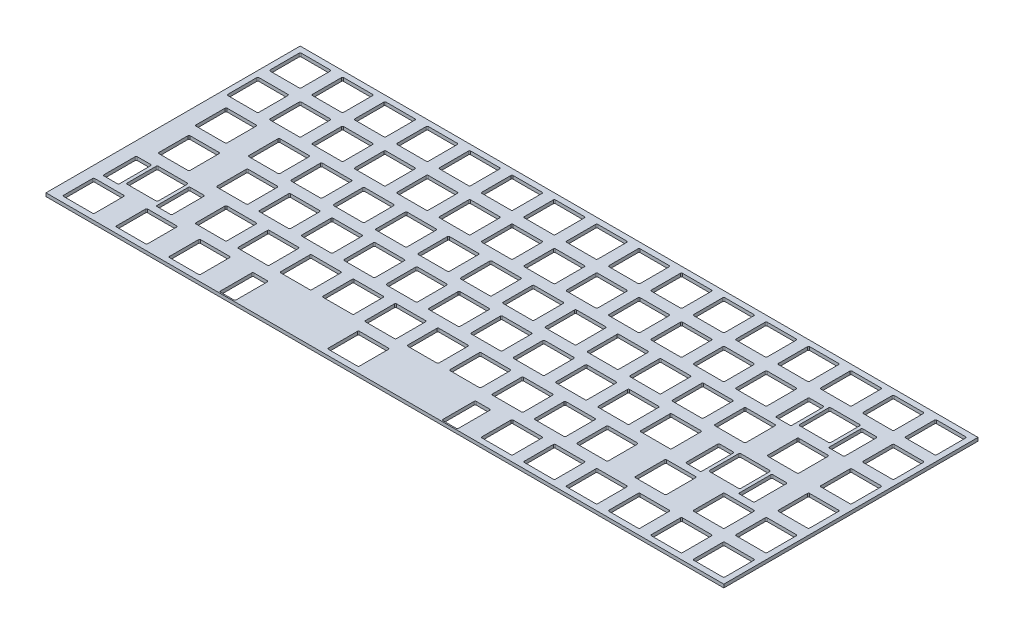
from build123d import *

# Parameters (mm, degrees)
SKETCH2_W           = 304.8
SKETCH2_H           = 114.3
BOSS_EXTRUDE1_DEPTH = 1.5


with BuildPart() as part:
    # Sketch2 → Boss-Extrude1 (new body)
    with BuildSketch(Plane(origin=(0, 0, 0), x_dir=(1, 0, 0), z_dir=(0, 1, 0))):
        with Locations((152.4, -57.15)):
            Rectangle(SKETCH2_W, SKETCH2_H)
        with BuildLine():
            Line((3.025, -2.525), (16.025, -2.525))
            ThreePointArc((16.025, -2.525), (16.378553391, -2.671446609), (16.525, -3.025))
            Line((16.525, -3.025), (16.525, -16.025))
            ThreePointArc((16.525, -16.025), (16.378553391, -16.378553391), (16.025, -16.525))
            Line((16.025, -16.525), (3.025, -16.525))
            ThreePointArc((3.025, -16.525), (2.671446609, -16.378553391), (2.525, -16.025))
            Line((2.525, -16.025), (2.525, -3.025))
            ThreePointArc((2.525, -3.025), (2.671446609, -2.671446609), (3.025, -2.525))
        make_face(mode=Mode.SUBTRACT)
        with BuildLine():
            Line((22.075, -2.525), (35.075, -2.525))
            ThreePointArc((35.075, -2.525), (35.428553391, -2.671446609), (35.575, -3.025))
            Line((35.575, -3.025), (35.575, -16.025))
            ThreePointArc((35.575, -16.025), (35.428553391, -16.378553391), (35.075, -16.525))
            Line((35.075, -16.525), (22.075, -16.525))
            ThreePointArc((22.075, -16.525), (21.721446609, -16.378553391), (21.575, -16.025))
            Line((21.575, -16.025), (21.575, -3.025))
            ThreePointArc((21.575, -3.025), (21.721446609, -2.671446609), (22.075, -2.525))
        make_face(mode=Mode.SUBTRACT)
        with BuildLine():
            Line((41.125, -2.525), (54.125, -2.525))
            ThreePointArc((54.125, -2.525), (54.478553391, -2.671446609), (54.625, -3.025))
            Line((54.625, -3.025), (54.625, -16.025))
            ThreePointArc((54.625, -16.025), (54.478553391, -16.378553391), (54.125, -16.525))
            Line((54.125, -16.525), (41.125, -16.525))
            ThreePointArc((41.125, -16.525), (40.771446609, -16.378553391), (40.625, -16.025))
            Line((40.625, -16.025), (40.625, -3.025))
            ThreePointArc((40.625, -3.025), (40.771446609, -2.671446609), (41.125, -2.525))
        make_face(mode=Mode.SUBTRACT)
        with BuildLine():
            Line((60.175, -2.525), (73.175, -2.525))
            ThreePointArc((73.175, -2.525), (73.528553391, -2.671446609), (73.675, -3.025))
            Line((73.675, -3.025), (73.675, -16.025))
            ThreePointArc((73.675, -16.025), (73.528553391, -16.378553391), (73.175, -16.525))
            Line((73.175, -16.525), (60.175, -16.525))
            ThreePointArc((60.175, -16.525), (59.821446609, -16.378553391), (59.675, -16.025))
            Line((59.675, -16.025), (59.675, -3.025))
            ThreePointArc((59.675, -3.025), (59.821446609, -2.671446609), (60.175, -2.525))
        make_face(mode=Mode.SUBTRACT)
        with BuildLine():
            Line((79.225, -2.525), (92.225, -2.525))
            ThreePointArc((92.225, -2.525), (92.578553391, -2.671446609), (92.725, -3.025))
            Line((92.725, -3.025), (92.725, -16.025))
            ThreePointArc((92.725, -16.025), (92.578553391, -16.378553391), (92.225, -16.525))
            Line((92.225, -16.525), (79.225, -16.525))
            ThreePointArc((79.225, -16.525), (78.871446609, -16.378553391), (78.725, -16.025))
            Line((78.725, -16.025), (78.725, -3.025))
            ThreePointArc((78.725, -3.025), (78.871446609, -2.671446609), (79.225, -2.525))
        make_face(mode=Mode.SUBTRACT)
        with BuildLine():
            Line((98.275, -2.525), (111.275, -2.525))
            ThreePointArc((111.275, -2.525), (111.628553391, -2.671446609), (111.775, -3.025))
            Line((111.775, -3.025), (111.775, -16.025))
            ThreePointArc((111.775, -16.025), (111.628553391, -16.378553391), (111.275, -16.525))
            Line((111.275, -16.525), (98.275, -16.525))
            ThreePointArc((98.275, -16.525), (97.921446609, -16.378553391), (97.775, -16.025))
            Line((97.775, -16.025), (97.775, -3.025))
            ThreePointArc((97.775, -3.025), (97.921446609, -2.671446609), (98.275, -2.525))
        make_face(mode=Mode.SUBTRACT)
        with BuildLine():
            Line((117.325, -2.525), (130.325, -2.525))
            ThreePointArc((130.325, -2.525), (130.678553391, -2.671446609), (130.825, -3.025))
            Line((130.825, -3.025), (130.825, -16.025))
            ThreePointArc((130.825, -16.025), (130.678553391, -16.378553391), (130.325, -16.525))
            Line((130.325, -16.525), (117.325, -16.525))
            ThreePointArc((117.325, -16.525), (116.971446609, -16.378553391), (116.825, -16.025))
            Line((116.825, -16.025), (116.825, -3.025))
            ThreePointArc((116.825, -3.025), (116.971446609, -2.671446609), (117.325, -2.525))
        make_face(mode=Mode.SUBTRACT)
        with BuildLine():
            Line((136.375, -2.525), (149.375, -2.525))
            ThreePointArc((149.375, -2.525), (149.728553391, -2.671446609), (149.875, -3.025))
            Line((149.875, -3.025), (149.875, -16.025))
            ThreePointArc((149.875, -16.025), (149.728553391, -16.378553391), (149.375, -16.525))
            Line((149.375, -16.525), (136.375, -16.525))
            ThreePointArc((136.375, -16.525), (136.021446609, -16.378553391), (135.875, -16.025))
            Line((135.875, -16.025), (135.875, -3.025))
            ThreePointArc((135.875, -3.025), (136.021446609, -2.671446609), (136.375, -2.525))
        make_face(mode=Mode.SUBTRACT)
        with BuildLine():
            Line((155.425, -2.525), (168.425, -2.525))
            ThreePointArc((168.425, -2.525), (168.778553391, -2.671446609), (168.925, -3.025))
            Line((168.925, -3.025), (168.925, -16.025))
            ThreePointArc((168.925, -16.025), (168.778553391, -16.378553391), (168.425, -16.525))
            Line((168.425, -16.525), (155.425, -16.525))
            ThreePointArc((155.425, -16.525), (155.071446609, -16.378553391), (154.925, -16.025))
            Line((154.925, -16.025), (154.925, -3.025))
            ThreePointArc((154.925, -3.025), (155.071446609, -2.671446609), (155.425, -2.525))
        make_face(mode=Mode.SUBTRACT)
        with BuildLine():
            Line((174.475, -2.525), (187.475, -2.525))
            ThreePointArc((187.475, -2.525), (187.828553391, -2.671446609), (187.975, -3.025))
            Line((187.975, -3.025), (187.975, -16.025))
            ThreePointArc((187.975, -16.025), (187.828553391, -16.378553391), (187.475, -16.525))
            Line((187.475, -16.525), (174.475, -16.525))
            ThreePointArc((174.475, -16.525), (174.121446609, -16.378553391), (173.975, -16.025))
            Line((173.975, -16.025), (173.975, -3.025))
            ThreePointArc((173.975, -3.025), (174.121446609, -2.671446609), (174.475, -2.525))
        make_face(mode=Mode.SUBTRACT)
        with BuildLine():
            Line((193.525, -2.525), (206.525, -2.525))
            ThreePointArc((206.525, -2.525), (206.878553391, -2.671446609), (207.025, -3.025))
            Line((207.025, -3.025), (207.025, -16.025))
            ThreePointArc((207.025, -16.025), (206.878553391, -16.378553391), (206.525, -16.525))
            Line((206.525, -16.525), (193.525, -16.525))
            ThreePointArc((193.525, -16.525), (193.171446609, -16.378553391), (193.025, -16.025))
            Line((193.025, -16.025), (193.025, -3.025))
            ThreePointArc((193.025, -3.025), (193.171446609, -2.671446609), (193.525, -2.525))
        make_face(mode=Mode.SUBTRACT)
        with BuildLine():
            Line((212.575, -2.525), (225.575, -2.525))
            ThreePointArc((225.575, -2.525), (225.928553391, -2.671446609), (226.075, -3.025))
            Line((226.075, -3.025), (226.075, -16.025))
            ThreePointArc((226.075, -16.025), (225.928553391, -16.378553391), (225.575, -16.525))
            Line((225.575, -16.525), (212.575, -16.525))
            ThreePointArc((212.575, -16.525), (212.221446609, -16.378553391), (212.075, -16.025))
            Line((212.075, -16.025), (212.075, -3.025))
            ThreePointArc((212.075, -3.025), (212.221446609, -2.671446609), (212.575, -2.525))
        make_face(mode=Mode.SUBTRACT)
        with BuildLine():
            Line((231.625, -2.525), (244.625, -2.525))
            ThreePointArc((244.625, -2.525), (244.978553391, -2.671446609), (245.125, -3.025))
            Line((245.125, -3.025), (245.125, -16.025))
            ThreePointArc((245.125, -16.025), (244.978553391, -16.378553391), (244.625, -16.525))
            Line((244.625, -16.525), (231.625, -16.525))
            ThreePointArc((231.625, -16.525), (231.271446609, -16.378553391), (231.125, -16.025))
            Line((231.125, -16.025), (231.125, -3.025))
            ThreePointArc((231.125, -3.025), (231.271446609, -2.671446609), (231.625, -2.525))
        make_face(mode=Mode.SUBTRACT)
        with BuildLine():
            Line((250.675, -2.525), (263.675, -2.525))
            ThreePointArc((263.675, -2.525), (264.028553391, -2.671446609), (264.175, -3.025))
            Line((264.175, -3.025), (264.175, -16.025))
            ThreePointArc((264.175, -16.025), (264.028553391, -16.378553391), (263.675, -16.525))
            Line((263.675, -16.525), (250.675, -16.525))
            ThreePointArc((250.675, -16.525), (250.321446609, -16.378553391), (250.175, -16.025))
            Line((250.175, -16.025), (250.175, -3.025))
            ThreePointArc((250.175, -3.025), (250.321446609, -2.671446609), (250.675, -2.525))
        make_face(mode=Mode.SUBTRACT)
        with BuildLine():
            Line((269.725, -2.525), (282.725, -2.525))
            ThreePointArc((282.725, -2.525), (283.078553391, -2.671446609), (283.225, -3.025))
            Line((283.225, -3.025), (283.225, -16.025))
            ThreePointArc((283.225, -16.025), (283.078553391, -16.378553391), (282.725, -16.525))
            Line((282.725, -16.525), (269.725, -16.525))
            ThreePointArc((269.725, -16.525), (269.371446609, -16.378553391), (269.225, -16.025))
            Line((269.225, -16.025), (269.225, -3.025))
            ThreePointArc((269.225, -3.025), (269.371446609, -2.671446609), (269.725, -2.525))
        make_face(mode=Mode.SUBTRACT)
        with BuildLine():
            Line((288.775, -2.525), (301.775, -2.525))
            ThreePointArc((301.775, -2.525), (302.128553391, -2.671446609), (302.275, -3.025))
            Line((302.275, -3.025), (302.275, -16.025))
            ThreePointArc((302.275, -16.025), (302.128553391, -16.378553391), (301.775, -16.525))
            Line((301.775, -16.525), (288.775, -16.525))
            ThreePointArc((288.775, -16.525), (288.421446609, -16.378553391), (288.275, -16.025))
            Line((288.275, -16.025), (288.275, -3.025))
            ThreePointArc((288.275, -3.025), (288.421446609, -2.671446609), (288.775, -2.525))
        make_face(mode=Mode.SUBTRACT)
        with BuildLine():
            Line((3.025, -21.575), (16.025, -21.575))
            ThreePointArc((16.025, -21.575), (16.378553391, -21.721446609), (16.525, -22.075))
            Line((16.525, -22.075), (16.525, -35.075))
            ThreePointArc((16.525, -35.075), (16.378553391, -35.428553391), (16.025, -35.575))
            Line((16.025, -35.575), (3.025, -35.575))
            ThreePointArc((3.025, -35.575), (2.671446609, -35.428553391), (2.525, -35.075))
            Line((2.525, -35.075), (2.525, -22.075))
            ThreePointArc((2.525, -22.075), (2.671446609, -21.721446609), (3.025, -21.575))
        make_face(mode=Mode.SUBTRACT)
        with BuildLine():
            Line((22.075, -21.575), (35.075, -21.575))
            ThreePointArc((35.075, -21.575), (35.428553391, -21.721446609), (35.575, -22.075))
            Line((35.575, -22.075), (35.575, -35.075))
            ThreePointArc((35.575, -35.075), (35.428553391, -35.428553391), (35.075, -35.575))
            Line((35.075, -35.575), (22.075, -35.575))
            ThreePointArc((22.075, -35.575), (21.721446609, -35.428553391), (21.575, -35.075))
            Line((21.575, -35.075), (21.575, -22.075))
            ThreePointArc((21.575, -22.075), (21.721446609, -21.721446609), (22.075, -21.575))
        make_face(mode=Mode.SUBTRACT)
        with BuildLine():
            Line((41.125, -21.575), (54.125, -21.575))
            ThreePointArc((54.125, -21.575), (54.478553391, -21.721446609), (54.625, -22.075))
            Line((54.625, -22.075), (54.625, -35.075))
            ThreePointArc((54.625, -35.075), (54.478553391, -35.428553391), (54.125, -35.575))
            Line((54.125, -35.575), (41.125, -35.575))
            ThreePointArc((41.125, -35.575), (40.771446609, -35.428553391), (40.625, -35.075))
            Line((40.625, -35.075), (40.625, -22.075))
            ThreePointArc((40.625, -22.075), (40.771446609, -21.721446609), (41.125, -21.575))
        make_face(mode=Mode.SUBTRACT)
        with BuildLine():
            Line((60.175, -21.575), (73.175, -21.575))
            ThreePointArc((73.175, -21.575), (73.528553391, -21.721446609), (73.675, -22.075))
            Line((73.675, -22.075), (73.675, -35.075))
            ThreePointArc((73.675, -35.075), (73.528553391, -35.428553391), (73.175, -35.575))
            Line((73.175, -35.575), (60.175, -35.575))
            ThreePointArc((60.175, -35.575), (59.821446609, -35.428553391), (59.675, -35.075))
            Line((59.675, -35.075), (59.675, -22.075))
            ThreePointArc((59.675, -22.075), (59.821446609, -21.721446609), (60.175, -21.575))
        make_face(mode=Mode.SUBTRACT)
        with BuildLine():
            Line((79.225, -21.575), (92.225, -21.575))
            ThreePointArc((92.225, -21.575), (92.578553391, -21.721446609), (92.725, -22.075))
            Line((92.725, -22.075), (92.725, -35.075))
            ThreePointArc((92.725, -35.075), (92.578553391, -35.428553391), (92.225, -35.575))
            Line((92.225, -35.575), (79.225, -35.575))
            ThreePointArc((79.225, -35.575), (78.871446609, -35.428553391), (78.725, -35.075))
            Line((78.725, -35.075), (78.725, -22.075))
            ThreePointArc((78.725, -22.075), (78.871446609, -21.721446609), (79.225, -21.575))
        make_face(mode=Mode.SUBTRACT)
        with BuildLine():
            Line((98.275, -21.575), (111.275, -21.575))
            ThreePointArc((111.275, -21.575), (111.628553391, -21.721446609), (111.775, -22.075))
            Line((111.775, -22.075), (111.775, -35.075))
            ThreePointArc((111.775, -35.075), (111.628553391, -35.428553391), (111.275, -35.575))
            Line((111.275, -35.575), (98.275, -35.575))
            ThreePointArc((98.275, -35.575), (97.921446609, -35.428553391), (97.775, -35.075))
            Line((97.775, -35.075), (97.775, -22.075))
            ThreePointArc((97.775, -22.075), (97.921446609, -21.721446609), (98.275, -21.575))
        make_face(mode=Mode.SUBTRACT)
        with BuildLine():
            Line((117.325, -21.575), (130.325, -21.575))
            ThreePointArc((130.325, -21.575), (130.678553391, -21.721446609), (130.825, -22.075))
            Line((130.825, -22.075), (130.825, -35.075))
            ThreePointArc((130.825, -35.075), (130.678553391, -35.428553391), (130.325, -35.575))
            Line((130.325, -35.575), (117.325, -35.575))
            ThreePointArc((117.325, -35.575), (116.971446609, -35.428553391), (116.825, -35.075))
            Line((116.825, -35.075), (116.825, -22.075))
            ThreePointArc((116.825, -22.075), (116.971446609, -21.721446609), (117.325, -21.575))
        make_face(mode=Mode.SUBTRACT)
        with BuildLine():
            Line((136.375, -21.575), (149.375, -21.575))
            ThreePointArc((149.375, -21.575), (149.728553391, -21.721446609), (149.875, -22.075))
            Line((149.875, -22.075), (149.875, -35.075))
            ThreePointArc((149.875, -35.075), (149.728553391, -35.428553391), (149.375, -35.575))
            Line((149.375, -35.575), (136.375, -35.575))
            ThreePointArc((136.375, -35.575), (136.021446609, -35.428553391), (135.875, -35.075))
            Line((135.875, -35.075), (135.875, -22.075))
            ThreePointArc((135.875, -22.075), (136.021446609, -21.721446609), (136.375, -21.575))
        make_face(mode=Mode.SUBTRACT)
        with BuildLine():
            Line((155.425, -21.575), (168.425, -21.575))
            ThreePointArc((168.425, -21.575), (168.778553391, -21.721446609), (168.925, -22.075))
            Line((168.925, -22.075), (168.925, -35.075))
            ThreePointArc((168.925, -35.075), (168.778553391, -35.428553391), (168.425, -35.575))
            Line((168.425, -35.575), (155.425, -35.575))
            ThreePointArc((155.425, -35.575), (155.071446609, -35.428553391), (154.925, -35.075))
            Line((154.925, -35.075), (154.925, -22.075))
            ThreePointArc((154.925, -22.075), (155.071446609, -21.721446609), (155.425, -21.575))
        make_face(mode=Mode.SUBTRACT)
        with BuildLine():
            Line((174.475, -21.575), (187.475, -21.575))
            ThreePointArc((187.475, -21.575), (187.828553391, -21.721446609), (187.975, -22.075))
            Line((187.975, -22.075), (187.975, -35.075))
            ThreePointArc((187.975, -35.075), (187.828553391, -35.428553391), (187.475, -35.575))
            Line((187.475, -35.575), (174.475, -35.575))
            ThreePointArc((174.475, -35.575), (174.121446609, -35.428553391), (173.975, -35.075))
            Line((173.975, -35.075), (173.975, -22.075))
            ThreePointArc((173.975, -22.075), (174.121446609, -21.721446609), (174.475, -21.575))
        make_face(mode=Mode.SUBTRACT)
        with BuildLine():
            Line((193.525, -21.575), (206.525, -21.575))
            ThreePointArc((206.525, -21.575), (206.878553391, -21.721446609), (207.025, -22.075))
            Line((207.025, -22.075), (207.025, -35.075))
            ThreePointArc((207.025, -35.075), (206.878553391, -35.428553391), (206.525, -35.575))
            Line((206.525, -35.575), (193.525, -35.575))
            ThreePointArc((193.525, -35.575), (193.171446609, -35.428553391), (193.025, -35.075))
            Line((193.025, -35.075), (193.025, -22.075))
            ThreePointArc((193.025, -22.075), (193.171446609, -21.721446609), (193.525, -21.575))
        make_face(mode=Mode.SUBTRACT)
        with BuildLine():
            Line((212.575, -21.575), (225.575, -21.575))
            ThreePointArc((225.575, -21.575), (225.928553391, -21.721446609), (226.075, -22.075))
            Line((226.075, -22.075), (226.075, -35.075))
            ThreePointArc((226.075, -35.075), (225.928553391, -35.428553391), (225.575, -35.575))
            Line((225.575, -35.575), (212.575, -35.575))
            ThreePointArc((212.575, -35.575), (212.221446609, -35.428553391), (212.075, -35.075))
            Line((212.075, -35.075), (212.075, -22.075))
            ThreePointArc((212.075, -22.075), (212.221446609, -21.721446609), (212.575, -21.575))
        make_face(mode=Mode.SUBTRACT)
        with BuildLine():
            Line((231.625, -21.575), (244.625, -21.575))
            ThreePointArc((244.625, -21.575), (244.978553391, -21.721446609), (245.125, -22.075))
            Line((245.125, -22.075), (245.125, -35.075))
            ThreePointArc((245.125, -35.075), (244.978553391, -35.428553391), (244.625, -35.575))
            Line((244.625, -35.575), (231.625, -35.575))
            ThreePointArc((231.625, -35.575), (231.271446609, -35.428553391), (231.125, -35.075))
            Line((231.125, -35.075), (231.125, -22.075))
            ThreePointArc((231.125, -22.075), (231.271446609, -21.721446609), (231.625, -21.575))
        make_face(mode=Mode.SUBTRACT)
        with BuildLine():
            Line((260.2, -21.575), (273.2, -21.575))
            ThreePointArc((273.2, -21.575), (273.553553391, -21.721446609), (273.7, -22.075))
            Line((273.7, -22.075), (273.7, -35.075))
            ThreePointArc((273.7, -35.075), (273.553553391, -35.428553391), (273.2, -35.575))
            Line((273.2, -35.575), (260.2, -35.575))
            ThreePointArc((260.2, -35.575), (259.846446609, -35.428553391), (259.7, -35.075))
            Line((259.7, -35.075), (259.7, -22.075))
            ThreePointArc((259.7, -22.075), (259.846446609, -21.721446609), (260.2, -21.575))
        make_face(mode=Mode.SUBTRACT)
        with BuildLine():
            Line((251.762, -22.575), (257.762, -22.575))
            ThreePointArc((257.762, -22.575), (258.115553391, -22.721446609), (258.262, -23.075))
            Line((258.262, -23.075), (258.262, -37.075))
            ThreePointArc((258.262, -37.075), (258.115553391, -37.428553391), (257.762, -37.575))
            Line((257.762, -37.575), (251.762, -37.575))
            ThreePointArc((251.762, -37.575), (251.408446609, -37.428553391), (251.262, -37.075))
            Line((251.262, -37.075), (251.262, -23.075))
            ThreePointArc((251.262, -23.075), (251.408446609, -22.721446609), (251.762, -22.575))
        make_face(mode=Mode.SUBTRACT)
        with BuildLine():
            Line((275.638, -22.575), (281.638, -22.575))
            ThreePointArc((281.638, -22.575), (281.991553391, -22.721446609), (282.138, -23.075))
            Line((282.138, -23.075), (282.138, -37.075))
            ThreePointArc((282.138, -37.075), (281.991553391, -37.428553391), (281.638, -37.575))
            Line((281.638, -37.575), (275.638, -37.575))
            ThreePointArc((275.638, -37.575), (275.284446609, -37.428553391), (275.138, -37.075))
            Line((275.138, -37.075), (275.138, -23.075))
            ThreePointArc((275.138, -23.075), (275.284446609, -22.721446609), (275.638, -22.575))
        make_face(mode=Mode.SUBTRACT)
        with BuildLine():
            Line((288.775, -21.575), (301.775, -21.575))
            ThreePointArc((301.775, -21.575), (302.128553391, -21.721446609), (302.275, -22.075))
            Line((302.275, -22.075), (302.275, -35.075))
            ThreePointArc((302.275, -35.075), (302.128553391, -35.428553391), (301.775, -35.575))
            Line((301.775, -35.575), (288.775, -35.575))
            ThreePointArc((288.775, -35.575), (288.421446609, -35.428553391), (288.275, -35.075))
            Line((288.275, -35.075), (288.275, -22.075))
            ThreePointArc((288.275, -22.075), (288.421446609, -21.721446609), (288.775, -21.575))
        make_face(mode=Mode.SUBTRACT)
        with BuildLine():
            Line((7.7875, -40.625), (20.7875, -40.625))
            ThreePointArc((20.7875, -40.625), (21.141053391, -40.771446609), (21.2875, -41.125))
            Line((21.2875, -41.125), (21.2875, -54.125))
            ThreePointArc((21.2875, -54.125), (21.141053391, -54.478553391), (20.7875, -54.625))
            Line((20.7875, -54.625), (7.7875, -54.625))
            ThreePointArc((7.7875, -54.625), (7.433946609, -54.478553391), (7.2875, -54.125))
            Line((7.2875, -54.125), (7.2875, -41.125))
            ThreePointArc((7.2875, -41.125), (7.433946609, -40.771446609), (7.7875, -40.625))
        make_face(mode=Mode.SUBTRACT)
        with BuildLine():
            Line((31.6, -40.625), (44.6, -40.625))
            ThreePointArc((44.6, -40.625), (44.953553391, -40.771446609), (45.1, -41.125))
            Line((45.1, -41.125), (45.1, -54.125))
            ThreePointArc((45.1, -54.125), (44.953553391, -54.478553391), (44.6, -54.625))
            Line((44.6, -54.625), (31.6, -54.625))
            ThreePointArc((31.6, -54.625), (31.246446609, -54.478553391), (31.1, -54.125))
            Line((31.1, -54.125), (31.1, -41.125))
            ThreePointArc((31.1, -41.125), (31.246446609, -40.771446609), (31.6, -40.625))
        make_face(mode=Mode.SUBTRACT)
        with BuildLine():
            Line((50.65, -40.625), (63.65, -40.625))
            ThreePointArc((63.65, -40.625), (64.003553391, -40.771446609), (64.15, -41.125))
            Line((64.15, -41.125), (64.15, -54.125))
            ThreePointArc((64.15, -54.125), (64.003553391, -54.478553391), (63.65, -54.625))
            Line((63.65, -54.625), (50.65, -54.625))
            ThreePointArc((50.65, -54.625), (50.296446609, -54.478553391), (50.15, -54.125))
            Line((50.15, -54.125), (50.15, -41.125))
            ThreePointArc((50.15, -41.125), (50.296446609, -40.771446609), (50.65, -40.625))
        make_face(mode=Mode.SUBTRACT)
        with BuildLine():
            Line((69.7, -40.625), (82.7, -40.625))
            ThreePointArc((82.7, -40.625), (83.053553391, -40.771446609), (83.2, -41.125))
            Line((83.2, -41.125), (83.2, -54.125))
            ThreePointArc((83.2, -54.125), (83.053553391, -54.478553391), (82.7, -54.625))
            Line((82.7, -54.625), (69.7, -54.625))
            ThreePointArc((69.7, -54.625), (69.346446609, -54.478553391), (69.2, -54.125))
            Line((69.2, -54.125), (69.2, -41.125))
            ThreePointArc((69.2, -41.125), (69.346446609, -40.771446609), (69.7, -40.625))
        make_face(mode=Mode.SUBTRACT)
        with BuildLine():
            Line((88.75, -40.625), (101.75, -40.625))
            ThreePointArc((101.75, -40.625), (102.103553391, -40.771446609), (102.25, -41.125))
            Line((102.25, -41.125), (102.25, -54.125))
            ThreePointArc((102.25, -54.125), (102.103553391, -54.478553391), (101.75, -54.625))
            Line((101.75, -54.625), (88.75, -54.625))
            ThreePointArc((88.75, -54.625), (88.396446609, -54.478553391), (88.25, -54.125))
            Line((88.25, -54.125), (88.25, -41.125))
            ThreePointArc((88.25, -41.125), (88.396446609, -40.771446609), (88.75, -40.625))
        make_face(mode=Mode.SUBTRACT)
        with BuildLine():
            Line((107.8, -40.625), (120.8, -40.625))
            ThreePointArc((120.8, -40.625), (121.153553391, -40.771446609), (121.3, -41.125))
            Line((121.3, -41.125), (121.3, -54.125))
            ThreePointArc((121.3, -54.125), (121.153553391, -54.478553391), (120.8, -54.625))
            Line((120.8, -54.625), (107.8, -54.625))
            ThreePointArc((107.8, -54.625), (107.446446609, -54.478553391), (107.3, -54.125))
            Line((107.3, -54.125), (107.3, -41.125))
            ThreePointArc((107.3, -41.125), (107.446446609, -40.771446609), (107.8, -40.625))
        make_face(mode=Mode.SUBTRACT)
        with BuildLine():
            Line((126.85, -40.625), (139.85, -40.625))
            ThreePointArc((139.85, -40.625), (140.203553391, -40.771446609), (140.35, -41.125))
            Line((140.35, -41.125), (140.35, -54.125))
            ThreePointArc((140.35, -54.125), (140.203553391, -54.478553391), (139.85, -54.625))
            Line((139.85, -54.625), (126.85, -54.625))
            ThreePointArc((126.85, -54.625), (126.496446609, -54.478553391), (126.35, -54.125))
            Line((126.35, -54.125), (126.35, -41.125))
            ThreePointArc((126.35, -41.125), (126.496446609, -40.771446609), (126.85, -40.625))
        make_face(mode=Mode.SUBTRACT)
        with BuildLine():
            Line((145.9, -40.625), (158.9, -40.625))
            ThreePointArc((158.9, -40.625), (159.253553391, -40.771446609), (159.4, -41.125))
            Line((159.4, -41.125), (159.4, -54.125))
            ThreePointArc((159.4, -54.125), (159.253553391, -54.478553391), (158.9, -54.625))
            Line((158.9, -54.625), (145.9, -54.625))
            ThreePointArc((145.9, -54.625), (145.546446609, -54.478553391), (145.4, -54.125))
            Line((145.4, -54.125), (145.4, -41.125))
            ThreePointArc((145.4, -41.125), (145.546446609, -40.771446609), (145.9, -40.625))
        make_face(mode=Mode.SUBTRACT)
        with BuildLine():
            Line((164.95, -40.625), (177.95, -40.625))
            ThreePointArc((177.95, -40.625), (178.303553391, -40.771446609), (178.45, -41.125))
            Line((178.45, -41.125), (178.45, -54.125))
            ThreePointArc((178.45, -54.125), (178.303553391, -54.478553391), (177.95, -54.625))
            Line((177.95, -54.625), (164.95, -54.625))
            ThreePointArc((164.95, -54.625), (164.596446609, -54.478553391), (164.45, -54.125))
            Line((164.45, -54.125), (164.45, -41.125))
            ThreePointArc((164.45, -41.125), (164.596446609, -40.771446609), (164.95, -40.625))
        make_face(mode=Mode.SUBTRACT)
        with BuildLine():
            Line((184, -40.625), (197, -40.625))
            ThreePointArc((197, -40.625), (197.353553391, -40.771446609), (197.5, -41.125))
            Line((197.5, -41.125), (197.5, -54.125))
            ThreePointArc((197.5, -54.125), (197.353553391, -54.478553391), (197, -54.625))
            Line((197, -54.625), (184, -54.625))
            ThreePointArc((184, -54.625), (183.646446609, -54.478553391), (183.5, -54.125))
            Line((183.5, -54.125), (183.5, -41.125))
            ThreePointArc((183.5, -41.125), (183.646446609, -40.771446609), (184, -40.625))
        make_face(mode=Mode.SUBTRACT)
        with BuildLine():
            Line((203.05, -40.625), (216.05, -40.625))
            ThreePointArc((216.05, -40.625), (216.403553391, -40.771446609), (216.55, -41.125))
            Line((216.55, -41.125), (216.55, -54.125))
            ThreePointArc((216.55, -54.125), (216.403553391, -54.478553391), (216.05, -54.625))
            Line((216.05, -54.625), (203.05, -54.625))
            ThreePointArc((203.05, -54.625), (202.696446609, -54.478553391), (202.55, -54.125))
            Line((202.55, -54.125), (202.55, -41.125))
            ThreePointArc((202.55, -41.125), (202.696446609, -40.771446609), (203.05, -40.625))
        make_face(mode=Mode.SUBTRACT)
        with BuildLine():
            Line((222.1, -40.625), (235.1, -40.625))
            ThreePointArc((235.1, -40.625), (235.453553391, -40.771446609), (235.6, -41.125))
            Line((235.6, -41.125), (235.6, -54.125))
            ThreePointArc((235.6, -54.125), (235.453553391, -54.478553391), (235.1, -54.625))
            Line((235.1, -54.625), (222.1, -54.625))
            ThreePointArc((222.1, -54.625), (221.746446609, -54.478553391), (221.6, -54.125))
            Line((221.6, -54.125), (221.6, -41.125))
            ThreePointArc((221.6, -41.125), (221.746446609, -40.771446609), (222.1, -40.625))
        make_face(mode=Mode.SUBTRACT)
        with BuildLine():
            Line((241.15, -40.625), (254.15, -40.625))
            ThreePointArc((254.15, -40.625), (254.503553391, -40.771446609), (254.65, -41.125))
            Line((254.65, -41.125), (254.65, -54.125))
            ThreePointArc((254.65, -54.125), (254.503553391, -54.478553391), (254.15, -54.625))
            Line((254.15, -54.625), (241.15, -54.625))
            ThreePointArc((241.15, -54.625), (240.796446609, -54.478553391), (240.65, -54.125))
            Line((240.65, -54.125), (240.65, -41.125))
            ThreePointArc((240.65, -41.125), (240.796446609, -40.771446609), (241.15, -40.625))
        make_face(mode=Mode.SUBTRACT)
        with BuildLine():
            Line((264.9625, -40.625), (277.9625, -40.625))
            ThreePointArc((277.9625, -40.625), (278.316053391, -40.771446609), (278.4625, -41.125))
            Line((278.4625, -41.125), (278.4625, -54.125))
            ThreePointArc((278.4625, -54.125), (278.316053391, -54.478553391), (277.9625, -54.625))
            Line((277.9625, -54.625), (264.9625, -54.625))
            ThreePointArc((264.9625, -54.625), (264.608946609, -54.478553391), (264.4625, -54.125))
            Line((264.4625, -54.125), (264.4625, -41.125))
            ThreePointArc((264.4625, -41.125), (264.608946609, -40.771446609), (264.9625, -40.625))
        make_face(mode=Mode.SUBTRACT)
        with BuildLine():
            Line((288.775, -40.625), (301.775, -40.625))
            ThreePointArc((301.775, -40.625), (302.128553391, -40.771446609), (302.275, -41.125))
            Line((302.275, -41.125), (302.275, -54.125))
            ThreePointArc((302.275, -54.125), (302.128553391, -54.478553391), (301.775, -54.625))
            Line((301.775, -54.625), (288.775, -54.625))
            ThreePointArc((288.775, -54.625), (288.421446609, -54.478553391), (288.275, -54.125))
            Line((288.275, -54.125), (288.275, -41.125))
            ThreePointArc((288.275, -41.125), (288.421446609, -40.771446609), (288.775, -40.625))
        make_face(mode=Mode.SUBTRACT)
        with BuildLine():
            Line((10.16875, -59.675), (23.16875, -59.675))
            ThreePointArc((23.16875, -59.675), (23.522303391, -59.821446609), (23.66875, -60.175))
            Line((23.66875, -60.175), (23.66875, -73.175))
            ThreePointArc((23.66875, -73.175), (23.522303391, -73.528553391), (23.16875, -73.675))
            Line((23.16875, -73.675), (10.16875, -73.675))
            ThreePointArc((10.16875, -73.675), (9.815196609, -73.528553391), (9.66875, -73.175))
            Line((9.66875, -73.175), (9.66875, -60.175))
            ThreePointArc((9.66875, -60.175), (9.815196609, -59.821446609), (10.16875, -59.675))
        make_face(mode=Mode.SUBTRACT)
        with BuildLine():
            Line((36.3625, -59.675), (49.3625, -59.675))
            ThreePointArc((49.3625, -59.675), (49.716053391, -59.821446609), (49.8625, -60.175))
            Line((49.8625, -60.175), (49.8625, -73.175))
            ThreePointArc((49.8625, -73.175), (49.716053391, -73.528553391), (49.3625, -73.675))
            Line((49.3625, -73.675), (36.3625, -73.675))
            ThreePointArc((36.3625, -73.675), (36.008946609, -73.528553391), (35.8625, -73.175))
            Line((35.8625, -73.175), (35.8625, -60.175))
            ThreePointArc((35.8625, -60.175), (36.008946609, -59.821446609), (36.3625, -59.675))
        make_face(mode=Mode.SUBTRACT)
        with BuildLine():
            Line((55.4125, -59.675), (68.4125, -59.675))
            ThreePointArc((68.4125, -59.675), (68.766053391, -59.821446609), (68.9125, -60.175))
            Line((68.9125, -60.175), (68.9125, -73.175))
            ThreePointArc((68.9125, -73.175), (68.766053391, -73.528553391), (68.4125, -73.675))
            Line((68.4125, -73.675), (55.4125, -73.675))
            ThreePointArc((55.4125, -73.675), (55.058946609, -73.528553391), (54.9125, -73.175))
            Line((54.9125, -73.175), (54.9125, -60.175))
            ThreePointArc((54.9125, -60.175), (55.058946609, -59.821446609), (55.4125, -59.675))
        make_face(mode=Mode.SUBTRACT)
        with BuildLine():
            Line((74.4625, -59.675), (87.4625, -59.675))
            ThreePointArc((87.4625, -59.675), (87.816053391, -59.821446609), (87.9625, -60.175))
            Line((87.9625, -60.175), (87.9625, -73.175))
            ThreePointArc((87.9625, -73.175), (87.816053391, -73.528553391), (87.4625, -73.675))
            Line((87.4625, -73.675), (74.4625, -73.675))
            ThreePointArc((74.4625, -73.675), (74.108946609, -73.528553391), (73.9625, -73.175))
            Line((73.9625, -73.175), (73.9625, -60.175))
            ThreePointArc((73.9625, -60.175), (74.108946609, -59.821446609), (74.4625, -59.675))
        make_face(mode=Mode.SUBTRACT)
        with BuildLine():
            Line((93.5125, -59.675), (106.5125, -59.675))
            ThreePointArc((106.5125, -59.675), (106.866053391, -59.821446609), (107.0125, -60.175))
            Line((107.0125, -60.175), (107.0125, -73.175))
            ThreePointArc((107.0125, -73.175), (106.866053391, -73.528553391), (106.5125, -73.675))
            Line((106.5125, -73.675), (93.5125, -73.675))
            ThreePointArc((93.5125, -73.675), (93.158946609, -73.528553391), (93.0125, -73.175))
            Line((93.0125, -73.175), (93.0125, -60.175))
            ThreePointArc((93.0125, -60.175), (93.158946609, -59.821446609), (93.5125, -59.675))
        make_face(mode=Mode.SUBTRACT)
        with BuildLine():
            Line((112.5625, -59.675), (125.5625, -59.675))
            ThreePointArc((125.5625, -59.675), (125.916053391, -59.821446609), (126.0625, -60.175))
            Line((126.0625, -60.175), (126.0625, -73.175))
            ThreePointArc((126.0625, -73.175), (125.916053391, -73.528553391), (125.5625, -73.675))
            Line((125.5625, -73.675), (112.5625, -73.675))
            ThreePointArc((112.5625, -73.675), (112.208946609, -73.528553391), (112.0625, -73.175))
            Line((112.0625, -73.175), (112.0625, -60.175))
            ThreePointArc((112.0625, -60.175), (112.208946609, -59.821446609), (112.5625, -59.675))
        make_face(mode=Mode.SUBTRACT)
        with BuildLine():
            Line((131.6125, -59.675), (144.6125, -59.675))
            ThreePointArc((144.6125, -59.675), (144.966053391, -59.821446609), (145.1125, -60.175))
            Line((145.1125, -60.175), (145.1125, -73.175))
            ThreePointArc((145.1125, -73.175), (144.966053391, -73.528553391), (144.6125, -73.675))
            Line((144.6125, -73.675), (131.6125, -73.675))
            ThreePointArc((131.6125, -73.675), (131.258946609, -73.528553391), (131.1125, -73.175))
            Line((131.1125, -73.175), (131.1125, -60.175))
            ThreePointArc((131.1125, -60.175), (131.258946609, -59.821446609), (131.6125, -59.675))
        make_face(mode=Mode.SUBTRACT)
        with BuildLine():
            Line((150.6625, -59.675), (163.6625, -59.675))
            ThreePointArc((163.6625, -59.675), (164.016053391, -59.821446609), (164.1625, -60.175))
            Line((164.1625, -60.175), (164.1625, -73.175))
            ThreePointArc((164.1625, -73.175), (164.016053391, -73.528553391), (163.6625, -73.675))
            Line((163.6625, -73.675), (150.6625, -73.675))
            ThreePointArc((150.6625, -73.675), (150.308946609, -73.528553391), (150.1625, -73.175))
            Line((150.1625, -73.175), (150.1625, -60.175))
            ThreePointArc((150.1625, -60.175), (150.308946609, -59.821446609), (150.6625, -59.675))
        make_face(mode=Mode.SUBTRACT)
        with BuildLine():
            Line((169.7125, -59.675), (182.7125, -59.675))
            ThreePointArc((182.7125, -59.675), (183.066053391, -59.821446609), (183.2125, -60.175))
            Line((183.2125, -60.175), (183.2125, -73.175))
            ThreePointArc((183.2125, -73.175), (183.066053391, -73.528553391), (182.7125, -73.675))
            Line((182.7125, -73.675), (169.7125, -73.675))
            ThreePointArc((169.7125, -73.675), (169.358946609, -73.528553391), (169.2125, -73.175))
            Line((169.2125, -73.175), (169.2125, -60.175))
            ThreePointArc((169.2125, -60.175), (169.358946609, -59.821446609), (169.7125, -59.675))
        make_face(mode=Mode.SUBTRACT)
        with BuildLine():
            Line((188.7625, -59.675), (201.7625, -59.675))
            ThreePointArc((201.7625, -59.675), (202.116053391, -59.821446609), (202.2625, -60.175))
            Line((202.2625, -60.175), (202.2625, -73.175))
            ThreePointArc((202.2625, -73.175), (202.116053391, -73.528553391), (201.7625, -73.675))
            Line((201.7625, -73.675), (188.7625, -73.675))
            ThreePointArc((188.7625, -73.675), (188.408946609, -73.528553391), (188.2625, -73.175))
            Line((188.2625, -73.175), (188.2625, -60.175))
            ThreePointArc((188.2625, -60.175), (188.408946609, -59.821446609), (188.7625, -59.675))
        make_face(mode=Mode.SUBTRACT)
        with BuildLine():
            Line((207.8125, -59.675), (220.8125, -59.675))
            ThreePointArc((220.8125, -59.675), (221.166053391, -59.821446609), (221.3125, -60.175))
            Line((221.3125, -60.175), (221.3125, -73.175))
            ThreePointArc((221.3125, -73.175), (221.166053391, -73.528553391), (220.8125, -73.675))
            Line((220.8125, -73.675), (207.8125, -73.675))
            ThreePointArc((207.8125, -73.675), (207.458946609, -73.528553391), (207.3125, -73.175))
            Line((207.3125, -73.175), (207.3125, -60.175))
            ThreePointArc((207.3125, -60.175), (207.458946609, -59.821446609), (207.8125, -59.675))
        make_face(mode=Mode.SUBTRACT)
        with BuildLine():
            Line((226.8625, -59.675), (239.8625, -59.675))
            ThreePointArc((239.8625, -59.675), (240.216053391, -59.821446609), (240.3625, -60.175))
            Line((240.3625, -60.175), (240.3625, -73.175))
            ThreePointArc((240.3625, -73.175), (240.216053391, -73.528553391), (239.8625, -73.675))
            Line((239.8625, -73.675), (226.8625, -73.675))
            ThreePointArc((226.8625, -73.675), (226.508946609, -73.528553391), (226.3625, -73.175))
            Line((226.3625, -73.175), (226.3625, -60.175))
            ThreePointArc((226.3625, -60.175), (226.508946609, -59.821446609), (226.8625, -59.675))
        make_face(mode=Mode.SUBTRACT)
        with BuildLine():
            Line((257.81875, -59.675), (270.81875, -59.675))
            ThreePointArc((270.81875, -59.675), (271.172303391, -59.821446609), (271.31875, -60.175))
            Line((271.31875, -60.175), (271.31875, -73.175))
            ThreePointArc((271.31875, -73.175), (271.172303391, -73.528553391), (270.81875, -73.675))
            Line((270.81875, -73.675), (257.81875, -73.675))
            ThreePointArc((257.81875, -73.675), (257.465196609, -73.528553391), (257.31875, -73.175))
            Line((257.31875, -73.175), (257.31875, -60.175))
            ThreePointArc((257.31875, -60.175), (257.465196609, -59.821446609), (257.81875, -59.675))
        make_face(mode=Mode.SUBTRACT)
        with BuildLine():
            Line((249.38075, -60.675), (255.38075, -60.675))
            ThreePointArc((255.38075, -60.675), (255.734303391, -60.821446609), (255.88075, -61.175))
            Line((255.88075, -61.175), (255.88075, -75.175))
            ThreePointArc((255.88075, -75.175), (255.734303391, -75.528553391), (255.38075, -75.675))
            Line((255.38075, -75.675), (249.38075, -75.675))
            ThreePointArc((249.38075, -75.675), (249.027196609, -75.528553391), (248.88075, -75.175))
            Line((248.88075, -75.175), (248.88075, -61.175))
            ThreePointArc((248.88075, -61.175), (249.027196609, -60.821446609), (249.38075, -60.675))
        make_face(mode=Mode.SUBTRACT)
        with BuildLine():
            Line((273.25675, -60.675), (279.25675, -60.675))
            ThreePointArc((279.25675, -60.675), (279.610303391, -60.821446609), (279.75675, -61.175))
            Line((279.75675, -61.175), (279.75675, -75.175))
            ThreePointArc((279.75675, -75.175), (279.610303391, -75.528553391), (279.25675, -75.675))
            Line((279.25675, -75.675), (273.25675, -75.675))
            ThreePointArc((273.25675, -75.675), (272.903196609, -75.528553391), (272.75675, -75.175))
            Line((272.75675, -75.175), (272.75675, -61.175))
            ThreePointArc((272.75675, -61.175), (272.903196609, -60.821446609), (273.25675, -60.675))
        make_face(mode=Mode.SUBTRACT)
        with BuildLine():
            Line((288.775, -59.675), (301.775, -59.675))
            ThreePointArc((301.775, -59.675), (302.128553391, -59.821446609), (302.275, -60.175))
            Line((302.275, -60.175), (302.275, -73.175))
            ThreePointArc((302.275, -73.175), (302.128553391, -73.528553391), (301.775, -73.675))
            Line((301.775, -73.675), (288.775, -73.675))
            ThreePointArc((288.775, -73.675), (288.421446609, -73.528553391), (288.275, -73.175))
            Line((288.275, -73.175), (288.275, -60.175))
            ThreePointArc((288.275, -60.175), (288.421446609, -59.821446609), (288.775, -59.675))
        make_face(mode=Mode.SUBTRACT)
        with BuildLine():
            Line((14.93125, -78.725), (27.93125, -78.725))
            ThreePointArc((27.93125, -78.725), (28.284803391, -78.871446609), (28.43125, -79.225))
            Line((28.43125, -79.225), (28.43125, -92.225))
            ThreePointArc((28.43125, -92.225), (28.284803391, -92.578553391), (27.93125, -92.725))
            Line((27.93125, -92.725), (14.93125, -92.725))
            ThreePointArc((14.93125, -92.725), (14.577696609, -92.578553391), (14.43125, -92.225))
            Line((14.43125, -92.225), (14.43125, -79.225))
            ThreePointArc((14.43125, -79.225), (14.577696609, -78.871446609), (14.93125, -78.725))
        make_face(mode=Mode.SUBTRACT)
        with BuildLine():
            Line((6.49325, -79.725), (12.49325, -79.725))
            ThreePointArc((12.49325, -79.725), (12.846803391, -79.871446609), (12.99325, -80.225))
            Line((12.99325, -80.225), (12.99325, -94.225))
            ThreePointArc((12.99325, -94.225), (12.846803391, -94.578553391), (12.49325, -94.725))
            Line((12.49325, -94.725), (6.49325, -94.725))
            ThreePointArc((6.49325, -94.725), (6.139696609, -94.578553391), (5.99325, -94.225))
            Line((5.99325, -94.225), (5.99325, -80.225))
            ThreePointArc((5.99325, -80.225), (6.139696609, -79.871446609), (6.49325, -79.725))
        make_face(mode=Mode.SUBTRACT)
        with BuildLine():
            Line((30.36925, -79.725), (36.36925, -79.725))
            ThreePointArc((36.36925, -79.725), (36.722803391, -79.871446609), (36.86925, -80.225))
            Line((36.86925, -80.225), (36.86925, -94.225))
            ThreePointArc((36.86925, -94.225), (36.722803391, -94.578553391), (36.36925, -94.725))
            Line((36.36925, -94.725), (30.36925, -94.725))
            ThreePointArc((30.36925, -94.725), (30.015696609, -94.578553391), (29.86925, -94.225))
            Line((29.86925, -94.225), (29.86925, -80.225))
            ThreePointArc((29.86925, -80.225), (30.015696609, -79.871446609), (30.36925, -79.725))
        make_face(mode=Mode.SUBTRACT)
        with BuildLine():
            Line((45.8875, -78.725), (58.8875, -78.725))
            ThreePointArc((58.8875, -78.725), (59.241053391, -78.871446609), (59.3875, -79.225))
            Line((59.3875, -79.225), (59.3875, -92.225))
            ThreePointArc((59.3875, -92.225), (59.241053391, -92.578553391), (58.8875, -92.725))
            Line((58.8875, -92.725), (45.8875, -92.725))
            ThreePointArc((45.8875, -92.725), (45.533946609, -92.578553391), (45.3875, -92.225))
            Line((45.3875, -92.225), (45.3875, -79.225))
            ThreePointArc((45.3875, -79.225), (45.533946609, -78.871446609), (45.8875, -78.725))
        make_face(mode=Mode.SUBTRACT)
        with BuildLine():
            Line((64.9375, -78.725), (77.9375, -78.725))
            ThreePointArc((77.9375, -78.725), (78.291053391, -78.871446609), (78.4375, -79.225))
            Line((78.4375, -79.225), (78.4375, -92.225))
            ThreePointArc((78.4375, -92.225), (78.291053391, -92.578553391), (77.9375, -92.725))
            Line((77.9375, -92.725), (64.9375, -92.725))
            ThreePointArc((64.9375, -92.725), (64.583946609, -92.578553391), (64.4375, -92.225))
            Line((64.4375, -92.225), (64.4375, -79.225))
            ThreePointArc((64.4375, -79.225), (64.583946609, -78.871446609), (64.9375, -78.725))
        make_face(mode=Mode.SUBTRACT)
        with BuildLine():
            Line((83.9875, -78.725), (96.9875, -78.725))
            ThreePointArc((96.9875, -78.725), (97.341053391, -78.871446609), (97.4875, -79.225))
            Line((97.4875, -79.225), (97.4875, -92.225))
            ThreePointArc((97.4875, -92.225), (97.341053391, -92.578553391), (96.9875, -92.725))
            Line((96.9875, -92.725), (83.9875, -92.725))
            ThreePointArc((83.9875, -92.725), (83.633946609, -92.578553391), (83.4875, -92.225))
            Line((83.4875, -92.225), (83.4875, -79.225))
            ThreePointArc((83.4875, -79.225), (83.633946609, -78.871446609), (83.9875, -78.725))
        make_face(mode=Mode.SUBTRACT)
        with BuildLine():
            Line((103.0375, -78.725), (116.0375, -78.725))
            ThreePointArc((116.0375, -78.725), (116.391053391, -78.871446609), (116.5375, -79.225))
            Line((116.5375, -79.225), (116.5375, -92.225))
            ThreePointArc((116.5375, -92.225), (116.391053391, -92.578553391), (116.0375, -92.725))
            Line((116.0375, -92.725), (103.0375, -92.725))
            ThreePointArc((103.0375, -92.725), (102.683946609, -92.578553391), (102.5375, -92.225))
            Line((102.5375, -92.225), (102.5375, -79.225))
            ThreePointArc((102.5375, -79.225), (102.683946609, -78.871446609), (103.0375, -78.725))
        make_face(mode=Mode.SUBTRACT)
        with BuildLine():
            Line((122.0875, -78.725), (135.0875, -78.725))
            ThreePointArc((135.0875, -78.725), (135.441053391, -78.871446609), (135.5875, -79.225))
            Line((135.5875, -79.225), (135.5875, -92.225))
            ThreePointArc((135.5875, -92.225), (135.441053391, -92.578553391), (135.0875, -92.725))
            Line((135.0875, -92.725), (122.0875, -92.725))
            ThreePointArc((122.0875, -92.725), (121.733946609, -92.578553391), (121.5875, -92.225))
            Line((121.5875, -92.225), (121.5875, -79.225))
            ThreePointArc((121.5875, -79.225), (121.733946609, -78.871446609), (122.0875, -78.725))
        make_face(mode=Mode.SUBTRACT)
        with BuildLine():
            Line((141.1375, -78.725), (154.1375, -78.725))
            ThreePointArc((154.1375, -78.725), (154.491053391, -78.871446609), (154.6375, -79.225))
            Line((154.6375, -79.225), (154.6375, -92.225))
            ThreePointArc((154.6375, -92.225), (154.491053391, -92.578553391), (154.1375, -92.725))
            Line((154.1375, -92.725), (141.1375, -92.725))
            ThreePointArc((141.1375, -92.725), (140.783946609, -92.578553391), (140.6375, -92.225))
            Line((140.6375, -92.225), (140.6375, -79.225))
            ThreePointArc((140.6375, -79.225), (140.783946609, -78.871446609), (141.1375, -78.725))
        make_face(mode=Mode.SUBTRACT)
        with BuildLine():
            Line((160.1875, -78.725), (173.1875, -78.725))
            ThreePointArc((173.1875, -78.725), (173.541053391, -78.871446609), (173.6875, -79.225))
            Line((173.6875, -79.225), (173.6875, -92.225))
            ThreePointArc((173.6875, -92.225), (173.541053391, -92.578553391), (173.1875, -92.725))
            Line((173.1875, -92.725), (160.1875, -92.725))
            ThreePointArc((160.1875, -92.725), (159.833946609, -92.578553391), (159.6875, -92.225))
            Line((159.6875, -92.225), (159.6875, -79.225))
            ThreePointArc((159.6875, -79.225), (159.833946609, -78.871446609), (160.1875, -78.725))
        make_face(mode=Mode.SUBTRACT)
        with BuildLine():
            Line((179.2375, -78.725), (192.2375, -78.725))
            ThreePointArc((192.2375, -78.725), (192.591053391, -78.871446609), (192.7375, -79.225))
            Line((192.7375, -79.225), (192.7375, -92.225))
            ThreePointArc((192.7375, -92.225), (192.591053391, -92.578553391), (192.2375, -92.725))
            Line((192.2375, -92.725), (179.2375, -92.725))
            ThreePointArc((179.2375, -92.725), (178.883946609, -92.578553391), (178.7375, -92.225))
            Line((178.7375, -92.225), (178.7375, -79.225))
            ThreePointArc((178.7375, -79.225), (178.883946609, -78.871446609), (179.2375, -78.725))
        make_face(mode=Mode.SUBTRACT)
        with BuildLine():
            Line((198.2875, -78.725), (211.2875, -78.725))
            ThreePointArc((211.2875, -78.725), (211.641053391, -78.871446609), (211.7875, -79.225))
            Line((211.7875, -79.225), (211.7875, -92.225))
            ThreePointArc((211.7875, -92.225), (211.641053391, -92.578553391), (211.2875, -92.725))
            Line((211.2875, -92.725), (198.2875, -92.725))
            ThreePointArc((198.2875, -92.725), (197.933946609, -92.578553391), (197.7875, -92.225))
            Line((197.7875, -92.225), (197.7875, -79.225))
            ThreePointArc((197.7875, -79.225), (197.933946609, -78.871446609), (198.2875, -78.725))
        make_face(mode=Mode.SUBTRACT)
        with BuildLine():
            Line((217.3375, -78.725), (230.3375, -78.725))
            ThreePointArc((230.3375, -78.725), (230.691053391, -78.871446609), (230.8375, -79.225))
            Line((230.8375, -79.225), (230.8375, -92.225))
            ThreePointArc((230.8375, -92.225), (230.691053391, -92.578553391), (230.3375, -92.725))
            Line((230.3375, -92.725), (217.3375, -92.725))
            ThreePointArc((217.3375, -92.725), (216.983946609, -92.578553391), (216.8375, -92.225))
            Line((216.8375, -92.225), (216.8375, -79.225))
            ThreePointArc((216.8375, -79.225), (216.983946609, -78.871446609), (217.3375, -78.725))
        make_face(mode=Mode.SUBTRACT)
        with BuildLine():
            Line((243.53125, -78.725), (256.53125, -78.725))
            ThreePointArc((256.53125, -78.725), (256.884803391, -78.871446609), (257.03125, -79.225))
            Line((257.03125, -79.225), (257.03125, -92.225))
            ThreePointArc((257.03125, -92.225), (256.884803391, -92.578553391), (256.53125, -92.725))
            Line((256.53125, -92.725), (243.53125, -92.725))
            ThreePointArc((243.53125, -92.725), (243.177696609, -92.578553391), (243.03125, -92.225))
            Line((243.03125, -92.225), (243.03125, -79.225))
            ThreePointArc((243.03125, -79.225), (243.177696609, -78.871446609), (243.53125, -78.725))
        make_face(mode=Mode.SUBTRACT)
        with BuildLine():
            Line((269.725, -78.725), (282.725, -78.725))
            ThreePointArc((282.725, -78.725), (283.078553391, -78.871446609), (283.225, -79.225))
            Line((283.225, -79.225), (283.225, -92.225))
            ThreePointArc((283.225, -92.225), (283.078553391, -92.578553391), (282.725, -92.725))
            Line((282.725, -92.725), (269.725, -92.725))
            ThreePointArc((269.725, -92.725), (269.371446609, -92.578553391), (269.225, -92.225))
            Line((269.225, -92.225), (269.225, -79.225))
            ThreePointArc((269.225, -79.225), (269.371446609, -78.871446609), (269.725, -78.725))
        make_face(mode=Mode.SUBTRACT)
        with BuildLine():
            Line((288.775, -78.725), (301.775, -78.725))
            ThreePointArc((301.775, -78.725), (302.128553391, -78.871446609), (302.275, -79.225))
            Line((302.275, -79.225), (302.275, -92.225))
            ThreePointArc((302.275, -92.225), (302.128553391, -92.578553391), (301.775, -92.725))
            Line((301.775, -92.725), (288.775, -92.725))
            ThreePointArc((288.775, -92.725), (288.421446609, -92.578553391), (288.275, -92.225))
            Line((288.275, -92.225), (288.275, -79.225))
            ThreePointArc((288.275, -79.225), (288.421446609, -78.871446609), (288.775, -78.725))
        make_face(mode=Mode.SUBTRACT)
        with BuildLine():
            Line((5.40625, -97.775), (18.40625, -97.775))
            ThreePointArc((18.40625, -97.775), (18.759803391, -97.921446609), (18.90625, -98.275))
            Line((18.90625, -98.275), (18.90625, -111.275))
            ThreePointArc((18.90625, -111.275), (18.759803391, -111.628553391), (18.40625, -111.775))
            Line((18.40625, -111.775), (5.40625, -111.775))
            ThreePointArc((5.40625, -111.775), (5.052696609, -111.628553391), (4.90625, -111.275))
            Line((4.90625, -111.275), (4.90625, -98.275))
            ThreePointArc((4.90625, -98.275), (5.052696609, -97.921446609), (5.40625, -97.775))
        make_face(mode=Mode.SUBTRACT)
        with BuildLine():
            Line((29.21875, -97.775), (42.21875, -97.775))
            ThreePointArc((42.21875, -97.775), (42.572303391, -97.921446609), (42.71875, -98.275))
            Line((42.71875, -98.275), (42.71875, -111.275))
            ThreePointArc((42.71875, -111.275), (42.572303391, -111.628553391), (42.21875, -111.775))
            Line((42.21875, -111.775), (29.21875, -111.775))
            ThreePointArc((29.21875, -111.775), (28.865196609, -111.628553391), (28.71875, -111.275))
            Line((28.71875, -111.275), (28.71875, -98.275))
            ThreePointArc((28.71875, -98.275), (28.865196609, -97.921446609), (29.21875, -97.775))
        make_face(mode=Mode.SUBTRACT)
        with BuildLine():
            Line((53.03125, -97.775), (66.03125, -97.775))
            ThreePointArc((66.03125, -97.775), (66.384803391, -97.921446609), (66.53125, -98.275))
            Line((66.53125, -98.275), (66.53125, -111.275))
            ThreePointArc((66.53125, -111.275), (66.384803391, -111.628553391), (66.03125, -111.775))
            Line((66.03125, -111.775), (53.03125, -111.775))
            ThreePointArc((53.03125, -111.775), (52.677696609, -111.628553391), (52.53125, -111.275))
            Line((52.53125, -111.275), (52.53125, -98.275))
            ThreePointArc((52.53125, -98.275), (52.677696609, -97.921446609), (53.03125, -97.775))
        make_face(mode=Mode.SUBTRACT)
        with BuildLine():
            Line((124.46875, -97.775), (137.46875, -97.775))
            ThreePointArc((137.46875, -97.775), (137.822303391, -97.921446609), (137.96875, -98.275))
            Line((137.96875, -98.275), (137.96875, -111.275))
            ThreePointArc((137.96875, -111.275), (137.822303391, -111.628553391), (137.46875, -111.775))
            Line((137.46875, -111.775), (124.46875, -111.775))
            ThreePointArc((124.46875, -111.775), (124.115196609, -111.628553391), (123.96875, -111.275))
            Line((123.96875, -111.275), (123.96875, -98.275))
            ThreePointArc((123.96875, -98.275), (124.115196609, -97.921446609), (124.46875, -97.775))
        make_face(mode=Mode.SUBTRACT)
        with BuildLine():
            Line((77.96875, -98.775), (83.96875, -98.775))
            ThreePointArc((83.96875, -98.775), (84.322303391, -98.921446609), (84.46875, -99.275))
            Line((84.46875, -99.275), (84.46875, -113.275))
            ThreePointArc((84.46875, -113.275), (84.322303391, -113.628553391), (83.96875, -113.775))
            Line((83.96875, -113.775), (77.96875, -113.775))
            ThreePointArc((77.96875, -113.775), (77.615196609, -113.628553391), (77.46875, -113.275))
            Line((77.46875, -113.275), (77.46875, -99.275))
            ThreePointArc((77.46875, -99.275), (77.615196609, -98.921446609), (77.96875, -98.775))
        make_face(mode=Mode.SUBTRACT)
        with BuildLine():
            Line((177.96875, -98.775), (183.96875, -98.775))
            ThreePointArc((183.96875, -98.775), (184.322303391, -98.921446609), (184.46875, -99.275))
            Line((184.46875, -99.275), (184.46875, -113.275))
            ThreePointArc((184.46875, -113.275), (184.322303391, -113.628553391), (183.96875, -113.775))
            Line((183.96875, -113.775), (177.96875, -113.775))
            ThreePointArc((177.96875, -113.775), (177.615196609, -113.628553391), (177.46875, -113.275))
            Line((177.46875, -113.275), (177.46875, -99.275))
            ThreePointArc((177.46875, -99.275), (177.615196609, -98.921446609), (177.96875, -98.775))
        make_face(mode=Mode.SUBTRACT)
        with BuildLine():
            Line((193.525, -97.775), (206.525, -97.775))
            ThreePointArc((206.525, -97.775), (206.878553391, -97.921446609), (207.025, -98.275))
            Line((207.025, -98.275), (207.025, -111.275))
            ThreePointArc((207.025, -111.275), (206.878553391, -111.628553391), (206.525, -111.775))
            Line((206.525, -111.775), (193.525, -111.775))
            ThreePointArc((193.525, -111.775), (193.171446609, -111.628553391), (193.025, -111.275))
            Line((193.025, -111.275), (193.025, -98.275))
            ThreePointArc((193.025, -98.275), (193.171446609, -97.921446609), (193.525, -97.775))
        make_face(mode=Mode.SUBTRACT)
        with BuildLine():
            Line((212.575, -97.775), (225.575, -97.775))
            ThreePointArc((225.575, -97.775), (225.928553391, -97.921446609), (226.075, -98.275))
            Line((226.075, -98.275), (226.075, -111.275))
            ThreePointArc((226.075, -111.275), (225.928553391, -111.628553391), (225.575, -111.775))
            Line((225.575, -111.775), (212.575, -111.775))
            ThreePointArc((212.575, -111.775), (212.221446609, -111.628553391), (212.075, -111.275))
            Line((212.075, -111.275), (212.075, -98.275))
            ThreePointArc((212.075, -98.275), (212.221446609, -97.921446609), (212.575, -97.775))
        make_face(mode=Mode.SUBTRACT)
        with BuildLine():
            Line((231.625, -97.775), (244.625, -97.775))
            ThreePointArc((244.625, -97.775), (244.978553391, -97.921446609), (245.125, -98.275))
            Line((245.125, -98.275), (245.125, -111.275))
            ThreePointArc((245.125, -111.275), (244.978553391, -111.628553391), (244.625, -111.775))
            Line((244.625, -111.775), (231.625, -111.775))
            ThreePointArc((231.625, -111.775), (231.271446609, -111.628553391), (231.125, -111.275))
            Line((231.125, -111.275), (231.125, -98.275))
            ThreePointArc((231.125, -98.275), (231.271446609, -97.921446609), (231.625, -97.775))
        make_face(mode=Mode.SUBTRACT)
        with BuildLine():
            Line((250.675, -97.775), (263.675, -97.775))
            ThreePointArc((263.675, -97.775), (264.028553391, -97.921446609), (264.175, -98.275))
            Line((264.175, -98.275), (264.175, -111.275))
            ThreePointArc((264.175, -111.275), (264.028553391, -111.628553391), (263.675, -111.775))
            Line((263.675, -111.775), (250.675, -111.775))
            ThreePointArc((250.675, -111.775), (250.321446609, -111.628553391), (250.175, -111.275))
            Line((250.175, -111.275), (250.175, -98.275))
            ThreePointArc((250.175, -98.275), (250.321446609, -97.921446609), (250.675, -97.775))
        make_face(mode=Mode.SUBTRACT)
        with BuildLine():
            Line((269.725, -97.775), (282.725, -97.775))
            ThreePointArc((282.725, -97.775), (283.078553391, -97.921446609), (283.225, -98.275))
            Line((283.225, -98.275), (283.225, -111.275))
            ThreePointArc((283.225, -111.275), (283.078553391, -111.628553391), (282.725, -111.775))
            Line((282.725, -111.775), (269.725, -111.775))
            ThreePointArc((269.725, -111.775), (269.371446609, -111.628553391), (269.225, -111.275))
            Line((269.225, -111.275), (269.225, -98.275))
            ThreePointArc((269.225, -98.275), (269.371446609, -97.921446609), (269.725, -97.775))
        make_face(mode=Mode.SUBTRACT)
        with BuildLine():
            Line((288.775, -97.775), (301.775, -97.775))
            ThreePointArc((301.775, -97.775), (302.128553391, -97.921446609), (302.275, -98.275))
            Line((302.275, -98.275), (302.275, -111.275))
            ThreePointArc((302.275, -111.275), (302.128553391, -111.628553391), (301.775, -111.775))
            Line((301.775, -111.775), (288.775, -111.775))
            ThreePointArc((288.775, -111.775), (288.421446609, -111.628553391), (288.275, -111.275))
            Line((288.275, -111.275), (288.275, -98.275))
            ThreePointArc((288.275, -98.275), (288.421446609, -97.921446609), (288.775, -97.775))
        make_face(mode=Mode.SUBTRACT)
    extrude(amount=BOSS_EXTRUDE1_DEPTH)


solid = part.part
